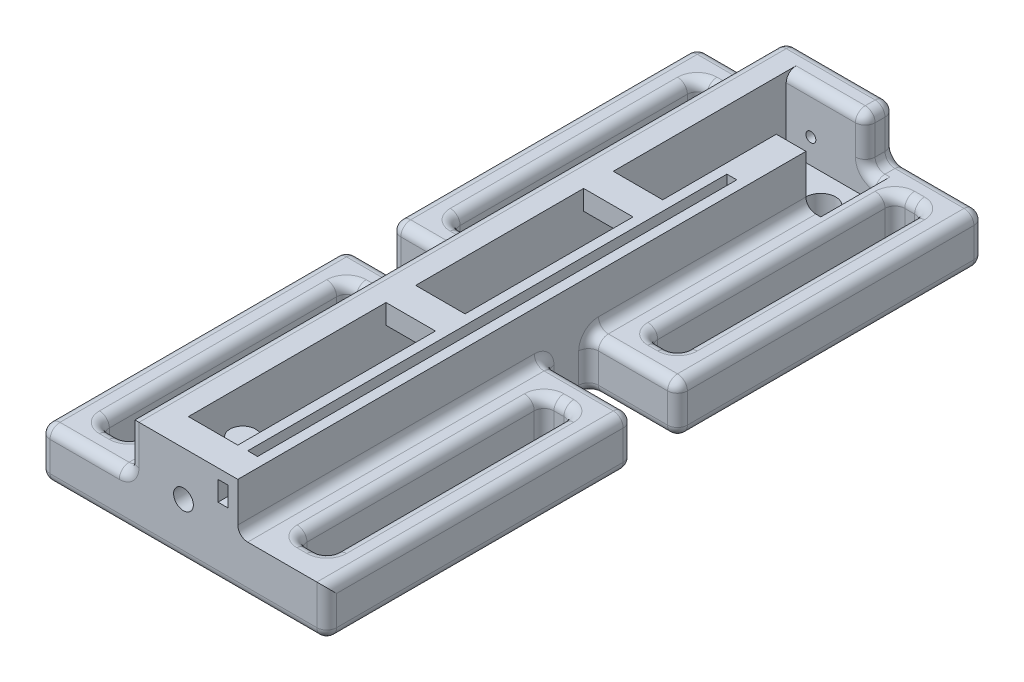
from build123d import *

# Parameters (mm, degrees)
SKETCH1_W           = 11
SKETCH1_H           = 66.5
BOSS_EXTRUDE2_DEPTH = 10
SKETCH2_W           = 5
SKETCH2_H           = 60.5
CUT_EXTRUDE1_DEPTH  = 7
SKETCH3_W           = 9
SKETCH3_H           = 31
SKETCH3_W_2         = 3
SKETCH3_H_2         = 25
BOSS_EXTRUDE3_DEPTH = 5
SKETCH4_R           = 1.3
BOSS_EXTRUDE4_DEPTH = 5
SKETCH5_W           = 5
SKETCH5_H           = 3
BOSS_EXTRUDE5_DEPTH = 2
SKETCH6_R           = 1.51
CUT_EXTRUDE4_DEPTH  = 10
SKETCH7_W           = 4.5
SKETCH7_H           = 6
CUT_EXTRUDE5_DEPTH  = 7
SKETCH10_R          = 0.5
CUT_EXTRUDE6_DEPTH  = 3
SKETCH11_R          = 1
CUT_EXTRUDE7_DEPTH  = 3
CUT_EXTRUDE8_DEPTH  = 3
SKETCH13_W          = 1
SKETCH13_H          = 2
CUT_EXTRUDE9_DEPTH  = 68
FILLET1_R           = 1


with BuildPart() as part:
    # Sketch1 → Boss-Extrude2 (new body)
    with BuildSketch(Plane(origin=(0, 0, 0), x_dir=(1, 0, 0), z_dir=(0, 1, 0))):
        with Locations((5.5, 33.25)):
            Rectangle(SKETCH1_W, SKETCH1_H)
    extrude(amount=BOSS_EXTRUDE2_DEPTH)

    # Sketch2 → Cut-Extrude1 (cut)
    with BuildSketch(Plane(origin=(0, 10, 0), x_dir=(1, 0, 0), z_dir=(0, 1, 0))):
        with Locations((5.5, 33.25)):
            Rectangle(SKETCH2_W, SKETCH2_H)
    extrude(amount=-CUT_EXTRUDE1_DEPTH, mode=Mode.SUBTRACT)

    # Sketch3 → Boss-Extrude3 (add)
    with BuildSketch(Plane(origin=(0, 0, 0), x_dir=(1, 0, 0), z_dir=(0, 1, 0))):
        with Locations((-4.5, 15.5)):
            Rectangle(SKETCH3_W, SKETCH3_H)
        with Locations((-4.5, 15.5)):
            Rectangle(SKETCH3_W_2, SKETCH3_H_2, mode=Mode.SUBTRACT)
        with Locations((15.5, 15.5)):
            Rectangle(SKETCH3_W, SKETCH3_H)
        with Locations((15.5, 15.5)):
            Rectangle(SKETCH3_W_2, SKETCH3_H_2, mode=Mode.SUBTRACT)
        with Locations((-4.5, 51)):
            Rectangle(SKETCH3_W, SKETCH3_H)
        with Locations((-4.5, 51)):
            Rectangle(SKETCH3_W_2, SKETCH3_H_2, mode=Mode.SUBTRACT)
        with Locations((15.5, 51)):
            Rectangle(SKETCH3_W, SKETCH3_H)
        with Locations((15.5, 51)):
            Rectangle(SKETCH3_W_2, SKETCH3_H_2, mode=Mode.SUBTRACT)
    extrude(amount=BOSS_EXTRUDE3_DEPTH)

    # Sketch4 → Boss-Extrude4 (add)
    with BuildSketch(Plane(origin=(0, 3, 0), x_dir=(1, 0, 0), z_dir=(0, 1, 0))):
        with Locations((5.5, 6)):
            Circle(SKETCH4_R)
    extrude(amount=BOSS_EXTRUDE4_DEPTH)

    # Sketch5 → Boss-Extrude5 (add)
    with BuildSketch(Plane(origin=(0, 10, 0), x_dir=(1, 0, 0), z_dir=(0, 1, 0))):
        with Locations((5.5, 24.5)):
            Rectangle(SKETCH5_W, SKETCH5_H)
        with Locations((5.5, 44.5)):
            Rectangle(SKETCH5_W, SKETCH5_H)
    extrude(amount=-BOSS_EXTRUDE5_DEPTH)

    # Sketch6 → Cut-Extrude4 (cut)
    with BuildSketch(Plane(origin=(0, 10, 0), x_dir=(1, 0, 0), z_dir=(0, 1, 0))):
        with Locations((9.5, 60.5)):
            Circle(SKETCH6_R)
    extrude(amount=-CUT_EXTRUDE4_DEPTH, mode=Mode.SUBTRACT)

    # Sketch7 → Cut-Extrude5 (cut)
    with BuildSketch(Plane(origin=(0, 10, 0), x_dir=(1, 0, 0), z_dir=(0, 1, 0))):
        with Locations((10.25, 60.5)):
            Rectangle(SKETCH7_W, SKETCH7_H)
    extrude(amount=-CUT_EXTRUDE5_DEPTH, mode=Mode.SUBTRACT)

    # Sketch10 → Cut-Extrude6 (cut)
    with BuildSketch(Plane.XY.offset(-66.5)):
        with Locations((5.5, 5.5)):
            Circle(SKETCH10_R)
    extrude(amount=CUT_EXTRUDE6_DEPTH, mode=Mode.SUBTRACT)

    # Sketch11 → Cut-Extrude7 (cut)
    with BuildSketch(Plane(origin=(0, 0, -3), x_dir=(-1, 0, 0), z_dir=(0, 0, -1))):
        with Locations((-5.5, 5.5)):
            Circle(SKETCH11_R)
    extrude(amount=-CUT_EXTRUDE7_DEPTH, mode=Mode.SUBTRACT)

    # Sketch12 → Cut-Extrude8 (cut)
    with BuildSketch(Plane(origin=(0, 10, 0), x_dir=(1, 0, 0), z_dir=(0, 1, 0))):
        Polygon((9, 11.5), (9, 3), (10, 3), (10, 11.5), (10, 14.5), (10, 23), (10, 26), (10, 33.437114061), (10, 36.408295957), (10, 43), (10, 46), (10, 51.5), (9, 51.5), (9, 46), (9, 43), (9, 36.408295957), (9, 33.437114061), (9, 26), (9, 23), (9, 14.5), align=None)
    extrude(amount=-CUT_EXTRUDE8_DEPTH, mode=Mode.SUBTRACT)

    # Sketch13 → Cut-Extrude9 (cut)
    with BuildSketch(Plane(origin=(0, 0, -57.5), x_dir=(-1, 0, 0), z_dir=(0, 0, -1))):
        with Locations((-9.5, 8)):
            Rectangle(SKETCH13_W, SKETCH13_H)
    extrude(amount=-CUT_EXTRUDE9_DEPTH, mode=Mode.SUBTRACT)

    # Fillet1
    fillet1_edges = [part.edges().sort_by_distance(p)[0] for p in [
        (15.5, 5, -66.5),
        (15.5, 5, -38.5),
        (15.5, 0, -38.5),
        (15.5, 5, -63.5),
        (15.5, 0, -63.5),
        (-4.5, 0, -38.5),
        (-4.5, 5, -38.5),
        (-4.5, 0, -63.5),
        (-4.5, 5, -63.5),
        (-4.5, 0, -28),
        (-4.5, 5, -28),
        (-4.5, 0, -3),
        (-4.5, 5, -3),
        (-4.5, 0, -35.5),
        (-4.5, 5, -35.5),
        (11, 5, -15.5),
        (11, 5, -46.5),
        (11, 0, -33.25),
        (15.5, 5, -28),
        (15.5, 0, -28),
        (15.5, 5, -3),
        (15.5, 0, -3),
        (11, 7.5, -66.5),
        (11, 5, -65),
        (11, 7.5, -63.5),
        (11, 10, -65),
        (14, 2.5, -3),
        (14, 5, -15.5),
        (14, 2.5, -28),
        (14, 0, -15.5),
        (17, 2.5, -63.5),
        (17, 5, -51),
        (17, 2.5, -38.5),
        (17, 0, -51),
        (14, 2.5, -38.5),
        (14, 5, -51),
        (14, 2.5, -63.5),
        (14, 0, -51),
        (-3, 2.5, -63.5),
        (-3, 2.5, -38.5),
        (-3, 0, -51),
        (-3, 5, -51),
        (-6, 2.5, -38.5),
        (-6, 2.5, -63.5),
        (-6, 0, -51),
        (-6, 5, -51),
        (-6, 2.5, -3),
        (-6, 2.5, -28),
        (-6, 0, -15.5),
        (-6, 5, -15.5),
        (-3, 2.5, -28),
        (-3, 2.5, -3),
        (-3, 0, -15.5),
        (-3, 5, -15.5),
        (0, 10, -33.25),
        (0, 7.5, 0),
        (0, 2.5, -31),
        (0, 0, -33.25),
        (0, 2.5, -35.5),
        (0, 7.5, -66.5),
        (15.5, 5, -31),
        (11, 2.5, -31),
        (15.5, 0, -31),
        (11, 2.5, -35.5),
        (15.5, 5, -35.5),
        (15.5, 0, -35.5),
        (20, 2.5, 0),
        (20, 5, -15.5),
        (20, 2.5, -31),
        (20, 0, -15.5),
        (17, 2.5, -28),
        (17, 5, -15.5),
        (17, 2.5, -3),
        (17, 0, -15.5),
        (20, 2.5, -35.5),
        (20, 5, -51),
        (20, 2.5, -66.5),
        (20, 0, -51),
        (-4.5, 5, 0),
        (-4.5, 5, -31),
        (0, 5, -15.5),
        (-4.5, 5, -66.5),
        (0, 5, -51),
        (-9, 2.5, -66.5),
        (-9, 5, -51),
        (-9, 2.5, -35.5),
        (-9, 0, -51),
        (-9, 2.5, -31),
        (-9, 5, -15.5),
        (-9, 2.5, 0),
        (-9, 0, -15.5),
        (11.75, 5, -63.5),
        (5.5, 0, 0),
        (5.5, 0, -66.5),
        (5.5, 10, -66.5),
        (7, 10, -63.5),
        (-4.5, 0, -31),
    ]]
    fillet(fillet1_edges, radius=FILLET1_R)


solid = part.part
